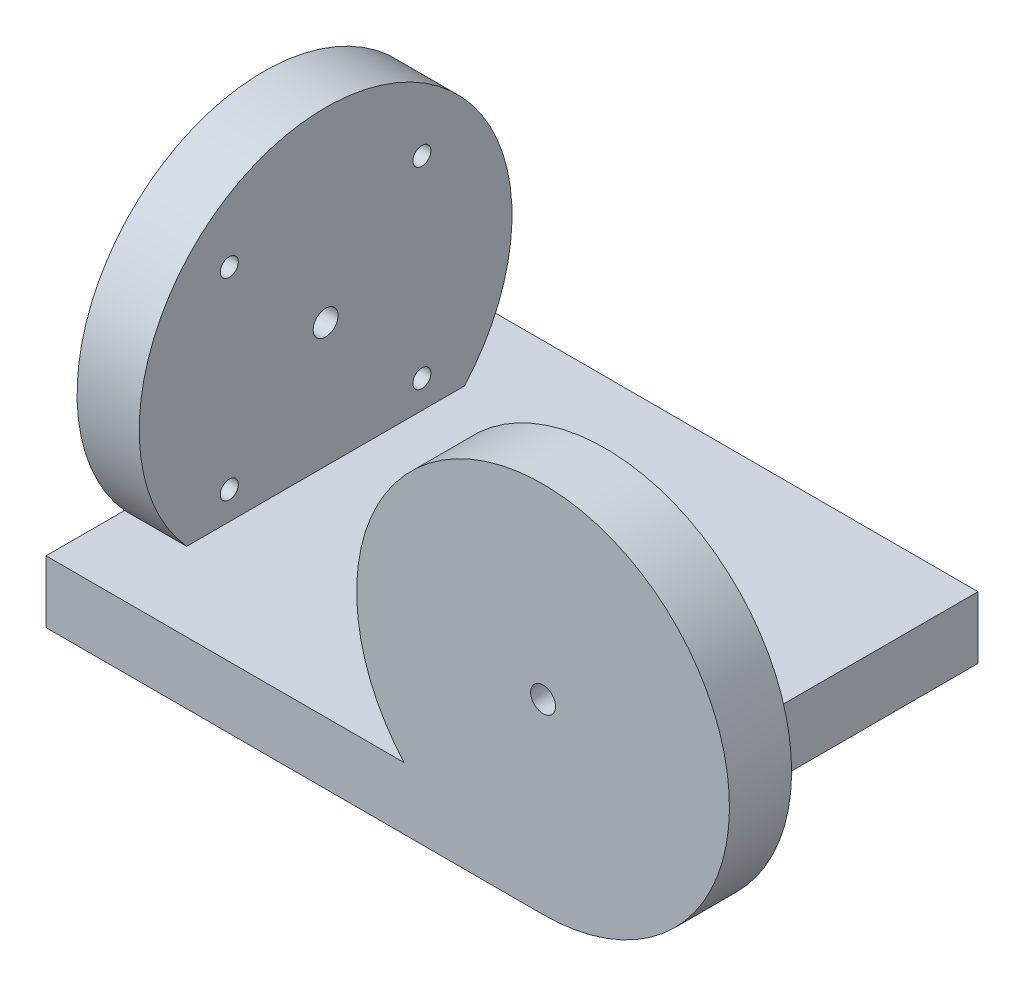
from build123d import *

# Parameters (mm, degrees)
SKETCH1_R                   = 30
BOSS_EXTRUDE1_DEPTH         = 10
SKETCH2_W                   = 80
SKETCH2_H                   = 10
BOSS_EXTRUDE2_DEPTH         = 70
SKETCH3_R                   = 30
BOSS_EXTRUDE3_DEPTH         = 10
F_4_0MM_DOWEL_HOLE1_D       = 4
F_4_0MM_DOWEL_HOLE1_DEPTH   = 10.1
F_4_0MM_DOWEL_HOLE1_TIP     = 1.201721238
M3_5X0_6_TAPPED_HOLE1_D     = 2.9
M3_5X0_6_TAPPED_HOLE1_DEPTH = 8.8
M3_5X0_6_TAPPED_HOLE1_TIP   = 0.871247898
F_4_0MM_DOWEL_HOLE5_D       = 4
F_4_0MM_DOWEL_HOLE5_DEPTH   = 10.1
F_4_0MM_DOWEL_HOLE5_TIP     = 1.201721238
M3_5X0_6_TAPPED_HOLE4_D     = 2.9
M3_5X0_6_TAPPED_HOLE4_DEPTH = 8.8
M3_5X0_6_TAPPED_HOLE4_TIP   = 0.871247898


with BuildPart() as part:
    # Sketch1 → Boss-Extrude1 (new body)
    with BuildSketch(Plane.XY):
        Circle(SKETCH1_R)
    extrude(amount=BOSS_EXTRUDE1_DEPTH)

    # Sketch2 → Boss-Extrude2 (add)
    with BuildSketch(Plane.XY.offset(10)):
        with Locations((-40, -25)):
            Rectangle(SKETCH2_W, SKETCH2_H)
    extrude(amount=-BOSS_EXTRUDE2_DEPTH)

    # Sketch3 → Boss-Extrude3 (add)
    with BuildSketch(Plane.ZY.offset(80)):
        with Locations((-25, 0)):
            Circle(SKETCH3_R)
    extrude(amount=-BOSS_EXTRUDE3_DEPTH)

    # Ø4.0mm Dowel Hole1
    with Locations(Plane(origin=(0, 0, 0), x_dir=(-1, 0, 0), z_dir=(0, 0, -1))):
        with Locations((0, 0)):
            Hole(F_4_0MM_DOWEL_HOLE1_D / 2, depth=F_4_0MM_DOWEL_HOLE1_DEPTH)
            with Locations((0, 0, -(F_4_0MM_DOWEL_HOLE1_DEPTH + F_4_0MM_DOWEL_HOLE1_TIP / 2))):  # 118° drill point
                Cone(0, F_4_0MM_DOWEL_HOLE1_D / 2, F_4_0MM_DOWEL_HOLE1_TIP, mode=Mode.SUBTRACT)

    # M3.5x0.6 Tapped Hole1
    with Locations(Plane(origin=(0, 0, 0), x_dir=(-1, 0, 0), z_dir=(0, 0, -1))):
        with Locations((-15.5, 15.5), (15.5, 15.5), (15.5, -15.5), (-15.5, -15.5)):
            Hole(M3_5X0_6_TAPPED_HOLE1_D / 2, depth=M3_5X0_6_TAPPED_HOLE1_DEPTH)
            with Locations((0, 0, -(M3_5X0_6_TAPPED_HOLE1_DEPTH + M3_5X0_6_TAPPED_HOLE1_TIP / 2))):  # 118° drill point
                Cone(0, M3_5X0_6_TAPPED_HOLE1_D / 2, M3_5X0_6_TAPPED_HOLE1_TIP, mode=Mode.SUBTRACT)

    # Ø4.0mm Dowel Hole5
    with Locations(Plane(origin=(-70, 13.498610341, 45.984792648), x_dir=(0, 0, -1), z_dir=(1, 0, 0))):
        with Locations((70.984792648, -13.498610341)):
            Hole(F_4_0MM_DOWEL_HOLE5_D / 2, depth=F_4_0MM_DOWEL_HOLE5_DEPTH)
            with Locations((0, 0, -(F_4_0MM_DOWEL_HOLE5_DEPTH + F_4_0MM_DOWEL_HOLE5_TIP / 2))):  # 118° drill point
                Cone(0, F_4_0MM_DOWEL_HOLE5_D / 2, F_4_0MM_DOWEL_HOLE5_TIP, mode=Mode.SUBTRACT)

    # M3.5x0.6 Tapped Hole4
    with Locations(Plane(origin=(-70, 0.743323111, -25.05678535), x_dir=(0, 0, -1), z_dir=(1, 0, 0))):
        with Locations((-15.55678535, 14.756676889), (15.44321465, 14.756676889), (15.44321465, -16.243323111), (-15.55678535, -16.243323111)):
            Hole(M3_5X0_6_TAPPED_HOLE4_D / 2, depth=M3_5X0_6_TAPPED_HOLE4_DEPTH)
            with Locations((0, 0, -(M3_5X0_6_TAPPED_HOLE4_DEPTH + M3_5X0_6_TAPPED_HOLE4_TIP / 2))):  # 118° drill point
                Cone(0, M3_5X0_6_TAPPED_HOLE4_D / 2, M3_5X0_6_TAPPED_HOLE4_TIP, mode=Mode.SUBTRACT)


solid = part.part
